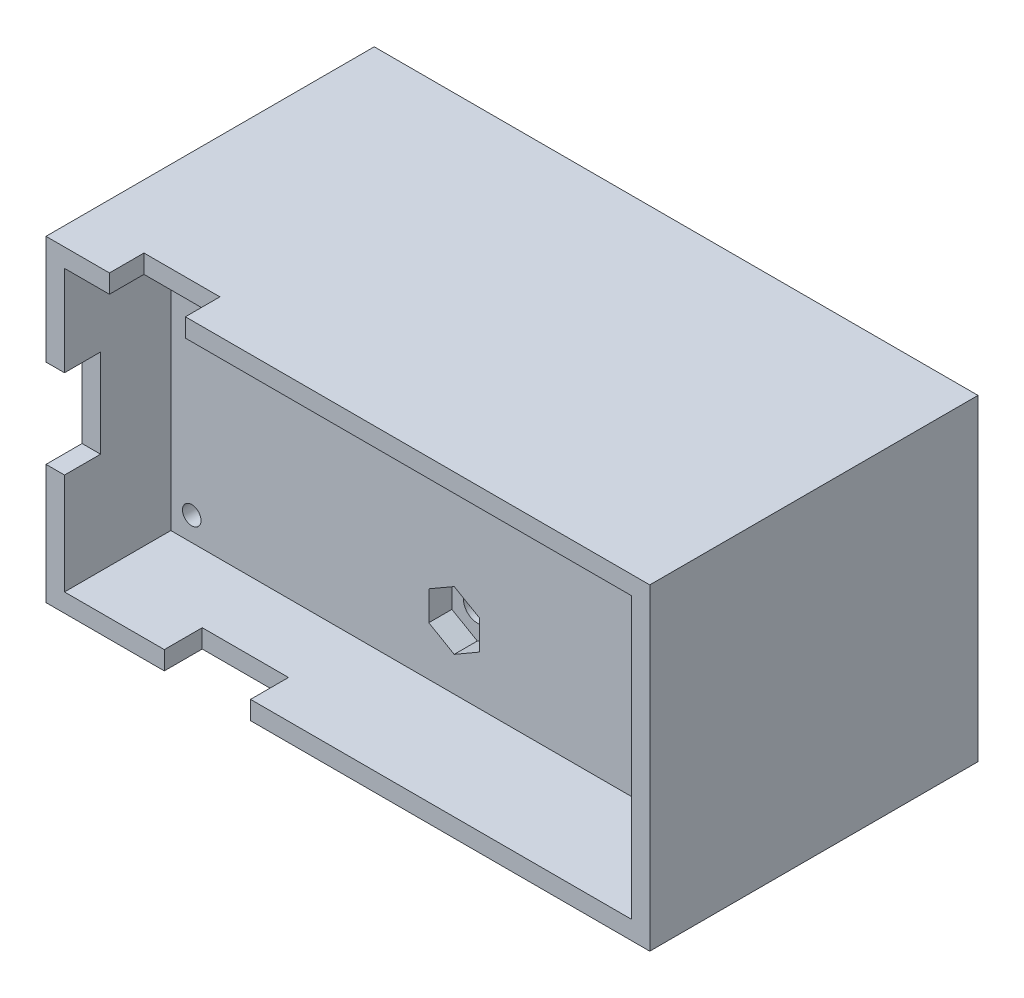
from build123d import *

# Parameters (mm, degrees)
SKETCH_2_W           = 65.2997206
SKETCH_2_H           = 34.311658624
SKETCH_2_R           = 1.00000254
SKETCH_2_R_2         = 0.922218434
SKETCH_2_R_3         = 1.5
EXTRUDE_2_DEPTH      = 4.5
SKETCH_3_R           = 1.5
CUT_EXTRUDE_2_DEPTH  = 2.5
SKETCH_5_W           = 65.2997206
SKETCH_5_H           = 34.311658624
SKETCH_5_W_2         = 61.2997206
SKETCH_5_H_2         = 30.311658624
EXTRUDE_3_DEPTH      = 15.5
EXTRUDE_3_DEPTH_BACK = 16
SKETCH_7_W           = 8.214112973
SKETCH_7_H           = 3.795011114
CUT_EXTRUDE_4_DEPTH  = 3
SKETCH_8_W           = 4
SKETCH_8_H           = 9.575559499
CUT_EXTRUDE_5_DEPTH  = 3
SKETCH_9_W           = 9.326303795
SKETCH_9_H           = 4.202278939
CUT_EXTRUDE_6_DEPTH  = 3
SKETCH_10_W          = 65.2997206
SKETCH_10_H          = 34.311658624
SKETCH_10_R          = 1
EXTRUDE_4_DEPTH      = 4


with BuildPart() as part:
    # 草图2 → 凸台-拉伸2 (new body)
    with BuildSketch(Plane(origin=(0, 0, -6), x_dir=(-1, 0, 0), z_dir=(0, 0, -1))):
        with Locations((29.273558547, -24.066548133)):
            Rectangle(SKETCH_2_W, SKETCH_2_H)
        with Locations((1.016002032, -11.24978156)):
            Circle(SKETCH_2_R, mode=Mode.SUBTRACT)
        with Locations((0.889001778, -36.83007366)):
            Circle(SKETCH_2_R, mode=Mode.SUBTRACT)
        with Locations((57.658115316, -36.64983236)):
            Circle(SKETCH_2_R, mode=Mode.SUBTRACT)
        with Locations((57.658115316, -11.24978156)):
            Circle(SKETCH_2_R_2, mode=Mode.SUBTRACT)
        with Locations((29.273558547, -32.316548133)):
            Circle(SKETCH_2_R_3, mode=Mode.SUBTRACT)
        with BuildLine():
            Line((27.785407033, -15.816548133), (27.785407033, -13.183619987))
            ThreePointArc((27.785407033, -13.183619987), (29.273558547, -11.695468472), (30.761710061, -13.183619987))
            Line((30.761710061, -13.183619987), (30.761710061, -15.816548133))
            ThreePointArc((30.761710061, -15.816548133), (29.273558547, -17.304699647), (27.785407033, -15.816548133))
        make_face(mode=Mode.SUBTRACT)
    extrude(amount=EXTRUDE_2_DEPTH)

    # 草图3 → 切除-拉伸2 (cut)
    with BuildSketch(Plane(origin=(0, 0, -6), x_dir=(-1, 0, 0), z_dir=(0, 0, -1))):
        Polygon((29.273558547, -18.991974614), (32.023558547, -17.404261373), (32.023558547, -14.920341582), (32.023558547, -14.228834893), (32.023558547, -11.744915102), (29.273558547, -10.157201862), (26.523558547, -11.744915102), (26.523558547, -14.228834893), (26.523558547, -14.920341582), (26.523558547, -17.404261373), align=None)
        with BuildLine():
            ThreePointArc((30.761710061, -15.816548133), (29.273558547, -17.304699647), (27.785407033, -15.816548133))
            Line((27.785407033, -15.816548133), (27.785407033, -13.183619987))
            ThreePointArc((27.785407033, -13.183619987), (29.273558547, -11.695468472), (30.761710061, -13.183619987))
            Line((30.761710061, -13.183619987), (30.761710061, -15.816548133))
        make_face(mode=Mode.SUBTRACT)
        Polygon((26.523558547, -30.728834893), (26.523558547, -33.904261373), (29.273558547, -35.491974614), (32.023558547, -33.904261373), (32.023558547, -30.728834893), (29.273558547, -29.141121653), align=None)
        with Locations((29.273558547, -32.316548133)):
            Circle(SKETCH_3_R, mode=Mode.SUBTRACT)
    extrude(amount=CUT_EXTRUDE_2_DEPTH, mode=Mode.SUBTRACT)

    # 草图5 → 凸台-拉伸3 (add, two sides)
    with BuildSketch(Plane(origin=(0, 0, -10.5), x_dir=(-1, 0, 0), z_dir=(0, 0, -1))) as extrude_3_sk:
        with Locations((29.273558547, -24.066548133)):
            Rectangle(SKETCH_5_W, SKETCH_5_H)
        with Locations((29.273558547, -24.066548133)):
            Rectangle(SKETCH_5_W_2, SKETCH_5_H_2, mode=Mode.SUBTRACT)
    extrude(amount=EXTRUDE_3_DEPTH)
    extrude(extrude_3_sk.sketch, amount=-EXTRUDE_3_DEPTH_BACK)

    # 草图7 → 切除-拉伸4 (cut)
    with BuildSketch(Plane(origin=(0, -6.910718821, 0), x_dir=(1, 0, 0), z_dir=(0, 1, 0))):
        with Locations((-50.955145133, -3.662545243)):
            Rectangle(SKETCH_7_W, SKETCH_7_H)
    extrude(amount=-CUT_EXTRUDE_4_DEPTH, mode=Mode.SUBTRACT)

    # 草图8 → 切除-拉伸5 (cut)
    with BuildSketch(Plane.ZY.offset(61.923418847)):
        with Locations((3.6000508, -23.483057223)):
            Rectangle(SKETCH_8_W, SKETCH_8_H)
    extrude(amount=-CUT_EXTRUDE_5_DEPTH, mode=Mode.SUBTRACT)

    # 草图9 → 切除-拉伸6 (cut)
    with BuildSketch(Plane.XZ.offset(41.222377445)):
        with Locations((-44.464129124, 3.49891133)):
            Rectangle(SKETCH_9_W, SKETCH_9_H)
    extrude(amount=-CUT_EXTRUDE_6_DEPTH, mode=Mode.SUBTRACT)

    # 草图10 → 凸台-拉伸4 (add)
    with BuildSketch(Plane(origin=(0, 0, -26), x_dir=(-1, 0, 0), z_dir=(0, 0, -1))):
        with Locations((29.273558547, -24.066548133)):
            Rectangle(SKETCH_10_W, SKETCH_10_H)
        Polygon((-1.376301753, -14.910718821), (-1.376301753, -8.910718821), (4.623698247, -8.910718821), (53.923418847, -8.910718821), (59.923418847, -8.910718821), (59.923418847, -14.910718821), (59.923418847, -33.222377445), (59.923418847, -39.222377445), (53.923418847, -39.222377445), (4.623698247, -39.222377445), (-1.376301753, -39.222377445), (-1.376301753, -33.222377445), align=None, mode=Mode.SUBTRACT)
        with BuildLine():
            Line((4.623698247, -8.910718821), (-1.376301753, -8.910718821))
            Line((-1.376301753, -8.910718821), (-1.376301753, -14.910718821))
            ThreePointArc((-1.376301753, -14.910718821), (2.866338935, -13.153359509), (4.623698247, -8.910718821))
        make_face()
        with Locations((1.016002032, -11.24978156)):
            Circle(SKETCH_10_R, mode=Mode.SUBTRACT)
        with BuildLine():
            ThreePointArc((4.623698247, -39.222377445), (2.866338935, -34.979736758), (-1.376301753, -33.222377445))
            Line((-1.376301753, -33.222377445), (-1.376301753, -39.222377445))
            Line((-1.376301753, -39.222377445), (4.623698247, -39.222377445))
        make_face()
        with Locations((1.016002032, -36.883314707)):
            Circle(SKETCH_10_R, mode=Mode.SUBTRACT)
        with BuildLine():
            Line((59.923418847, -39.222377445), (59.923418847, -33.222377445))
            ThreePointArc((59.923418847, -33.222377445), (55.68077816, -34.979736758), (53.923418847, -39.222377445))
            Line((53.923418847, -39.222377445), (59.923418847, -39.222377445))
        make_face()
        with Locations((57.658115316, -36.883314707)):
            Circle(SKETCH_10_R, mode=Mode.SUBTRACT)
        with BuildLine():
            Line((59.923418847, -8.910718821), (53.923418847, -8.910718821))
            ThreePointArc((53.923418847, -8.910718821), (55.68077816, -13.153359509), (59.923418847, -14.910718821))
            Line((59.923418847, -14.910718821), (59.923418847, -8.910718821))
        make_face()
        with Locations((57.658115316, -11.24978156)):
            Circle(SKETCH_10_R, mode=Mode.SUBTRACT)
    extrude(amount=EXTRUDE_4_DEPTH)


solid = part.part
